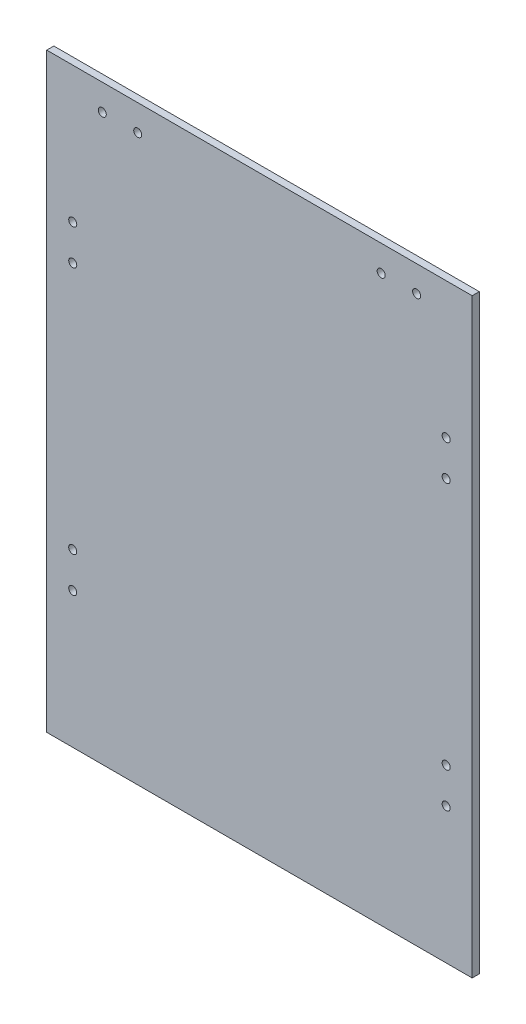
from build123d import *

# Parameters (mm, degrees)
ESQUISSE1_W             = 180
ESQUISSE1_H             = 250
BOSS_EXTRU_1_DEPTH      = 1.5
ESQUISSE2_R             = 1.7
ENL_V_MAT_EXTRU_1_DEPTH = 4
ESQUISSE3_R             = 1.7
ENL_V_MAT_EXTRU_2_DEPTH = 4


with BuildPart() as part:
    # Esquisse1 → Boss.-Extru.1 (new body, symmetric)
    with BuildSketch(Plane.XY):
        Rectangle(ESQUISSE1_W, ESQUISSE1_H)
    extrude(amount=BOSS_EXTRU_1_DEPTH, both=True)

    # Esquisse2 → Enlèv. mat.-Extru.1 (cut, through all)
    with BuildSketch(Plane.XY.offset(1.5)):
        with Locations((-51.5, 114)):
            Circle(ESQUISSE2_R)
        with Locations((-66.5, 114)):
            Circle(ESQUISSE2_R)
        with Locations((51.5, 114)):
            Circle(ESQUISSE2_R)
        with Locations((66.5, 114)):
            Circle(ESQUISSE2_R)
    extrude(amount=-ENL_V_MAT_EXTRU_1_DEPTH, mode=Mode.SUBTRACT)

    # Esquisse3 → Enlèv. mat.-Extru.2 (cut, through all)
    with BuildSketch(Plane.XY.offset(1.5)):
        with Locations((-79, 67.5)):
            Circle(ESQUISSE3_R)
        with Locations((-79, 52.5)):
            Circle(ESQUISSE3_R)
        with Locations((-79, -52.5)):
            Circle(ESQUISSE3_R)
        with Locations((-79, -67.5)):
            Circle(ESQUISSE3_R)
        with Locations((79, -67.5)):
            Circle(ESQUISSE3_R)
        with Locations((79, -52.5)):
            Circle(ESQUISSE3_R)
        with Locations((79, 52.5)):
            Circle(ESQUISSE3_R)
        with Locations((79, 67.5)):
            Circle(ESQUISSE3_R)
    extrude(amount=-ENL_V_MAT_EXTRU_2_DEPTH, mode=Mode.SUBTRACT)


solid = part.part
